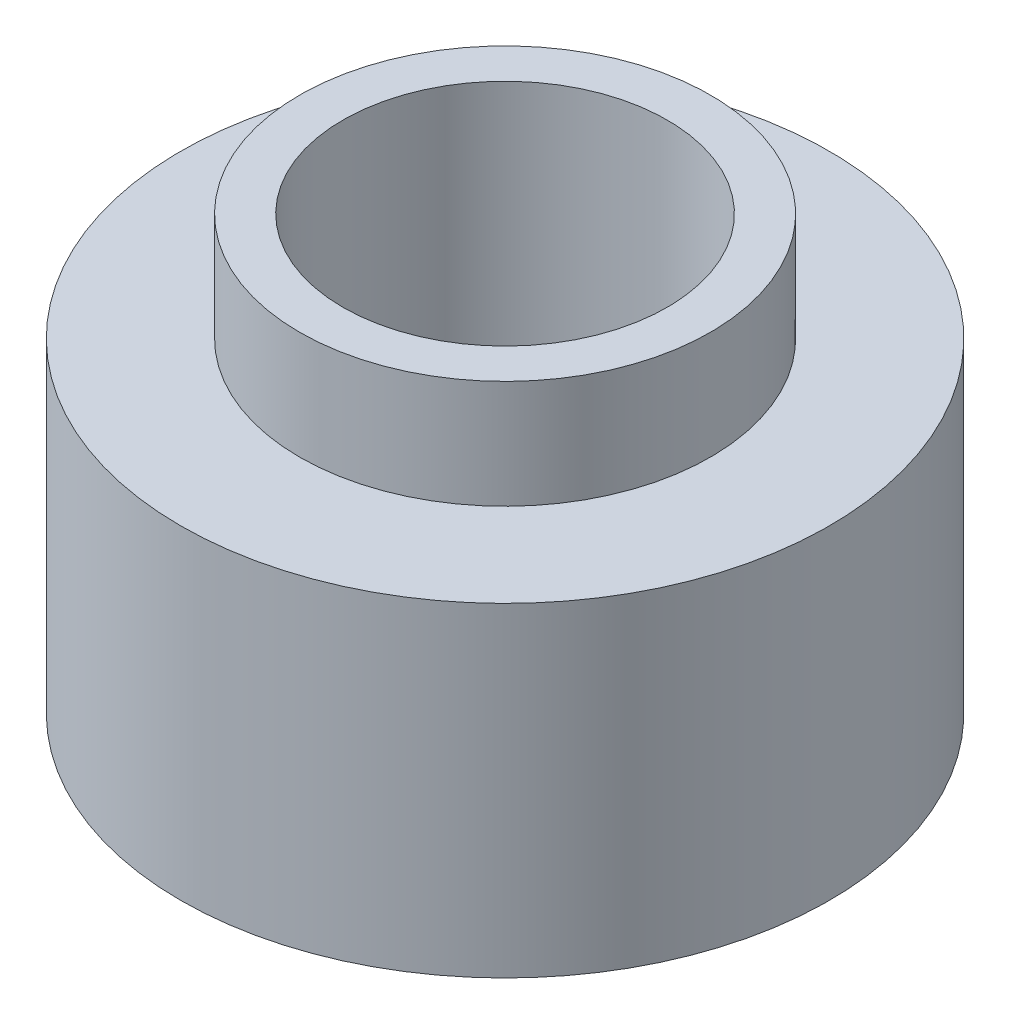
from build123d import *


with BuildPart() as part:
    # Sketch1 → Revolve1 (revolve)
    with BuildSketch(Plane.XY):
        Polygon((4.7625, 0), (4.7625, 12.7), (6.0325, 12.7), (6.0325, 9.525), (9.525, 9.525), (9.525, 0), align=None)
    revolve(axis=Axis((0, 9.238474184, 0), (0, -1, 0)))


solid = part.part
